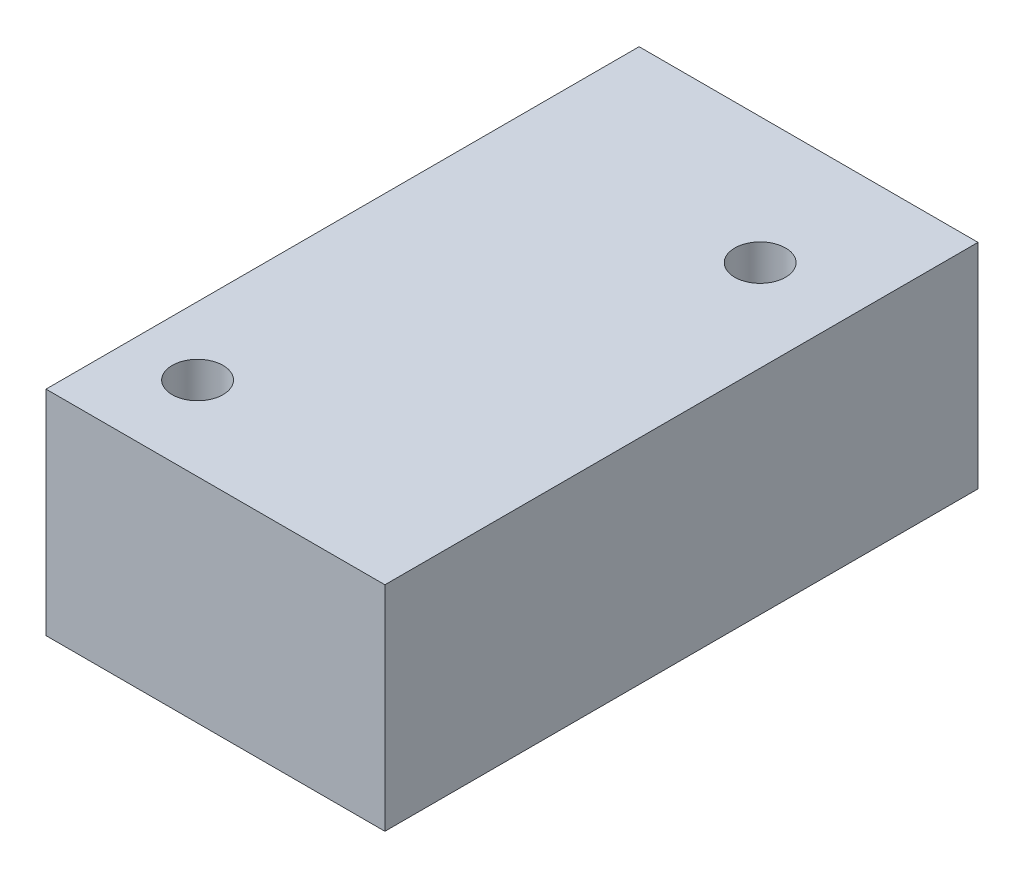
from build123d import *

# Parameters (mm, degrees)
SKETCH1_W           = 20
SKETCH1_H           = 35
BOSS_EXTRUDE1_DEPTH = 12.6
CUT_EXTRUDE1_REACH  = 14.6
SKETCH2_R           = 1.5


with BuildPart() as part:
    # Sketch1 → Boss-Extrude1 (new body)
    with BuildSketch(Plane(origin=(0, 0, 0), x_dir=(1, 0, 0), z_dir=(0, 1, 0))):
        Rectangle(SKETCH1_W, SKETCH1_H)
    extrude(amount=BOSS_EXTRUDE1_DEPTH)

    # Sketch2 → Cut-Extrude1 (cut, up to next)
    with BuildSketch(Plane.XZ, mode=Mode.PRIVATE) as cut_extrude1_sk1:
        with Locations((-5.990644946, 12.563355097)):
            Circle(SKETCH2_R)
    cut_extrude1_tool1 = extrude(cut_extrude1_sk1.sketch, amount=-CUT_EXTRUDE1_REACH, mode=Mode.PRIVATE) & part.part
    add(cut_extrude1_tool1.solids().sort_by_distance((-5.990645, 0, 12.563355))[0], mode=Mode.SUBTRACT)
    # Sketch2 → Cut-Extrude1 (cut, up to next)
    with BuildSketch(Plane.XZ, mode=Mode.PRIVATE) as cut_extrude1_sk2:
        with Locations((4.609355054, -10.036644903)):
            Circle(SKETCH2_R)
    cut_extrude1_tool2 = extrude(cut_extrude1_sk2.sketch, amount=-CUT_EXTRUDE1_REACH, mode=Mode.PRIVATE) & part.part
    add(cut_extrude1_tool2.solids().sort_by_distance((4.609355, 0, -10.036645))[0], mode=Mode.SUBTRACT)


solid = part.part
